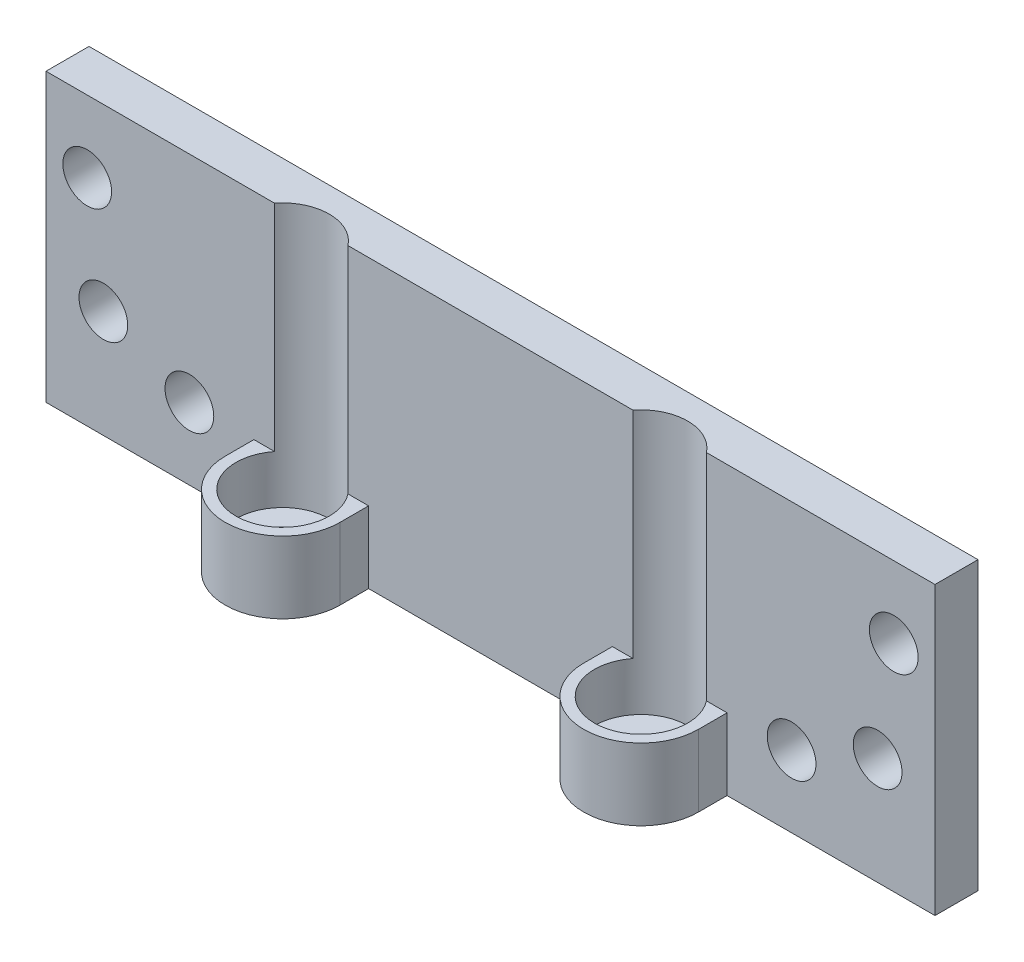
from build123d import *

# Parameters (mm, degrees)
BOSS_EXTRUDE1_DEPTH                          = 20
SKETCH2_W                                    = 33
SKETCH2_H                                    = 6
CUT_EXTRUDE1_DEPTH                           = 15
CBORE_FOR_M3_HEX_SOCKET_HEAD_CAP_SCR_2_COUNT = 2
CBORE_FOR_M3_HEX_SOCKET_HEAD_CAP_SCR_2_PITCH = 25
CUT_EXTRUDE2_DEPTH                           = 15
M3_CLEARANCE_HOLE1_D                         = 3.4
M3_CLEARANCE_HOLE1_DEPTH                     = 3


with BuildPart() as part:
    # Sketch1 → Boss-Extrude1 (new body)
    with BuildSketch(Plane(origin=(0, 0, 0), x_dir=(1, 0, 0), z_dir=(0, 1, 0))):
        with BuildLine():
            Line((-31, -1.5), (-16.5, -1.5))
            Line((-16.5, -1.5), (-16.5, -3.5))
            ThreePointArc((-16.5, -3.5), (-12.5, -7.5), (-8.5, -3.5))
            Line((-8.5, -3.5), (-8.5, -1.5))
            Line((-8.5, -1.5), (8.5, -1.5))
            Line((8.5, -1.5), (8.5, -3.5))
            ThreePointArc((8.5, -3.5), (12.5, -7.5), (16.5, -3.5))
            Line((16.5, -3.5), (16.5, -1.5))
            Line((16.5, -1.5), (31, -1.5))
            Line((31, -1.5), (31, 1.5))
            Line((31, 1.5), (-31, 1.5))
            Line((-31, 1.5), (-31, -1.5))
        make_face()
    extrude(amount=BOSS_EXTRUDE1_DEPTH)

    # Sketch2 → Cut-Extrude1 (cut)
    with BuildSketch(Plane(origin=(0, 20, 0), x_dir=(1, 0, 0), z_dir=(0, 1, 0))):
        with Locations((0, -4.5)):
            Rectangle(SKETCH2_W, SKETCH2_H)
    extrude(amount=-CUT_EXTRUDE1_DEPTH, mode=Mode.SUBTRACT)

    # Sketch4 → CBORE for M3 Hex Socket Head Cap Screw1 (revolve, cut)
    with BuildSketch(Plane(origin=(-12.5, 5, 3.5), x_dir=(0, 0, 1), z_dir=(1, 0, 0))):
        Polygon((0, 0), (0, 5), (1.6, 5), (1.6, 3.4), (3.25, 3.4), (3.25, 0), align=None)
    cbore_for_m3_hex_socket_head_cap_screw1 = revolve(axis=Axis((-12.5, 11.35, 3.5), (0, -1, 0)), mode=Mode.SUBTRACT)

    # CBORE for M3 Hex Socket Head Cap Scr 2: CBORE for M3 Hex Socket Head Cap Screw1 ×2
    with Locations(*[(i * CBORE_FOR_M3_HEX_SOCKET_HEAD_CAP_SCR_2_PITCH, 0, 0) for i in range(1, CBORE_FOR_M3_HEX_SOCKET_HEAD_CAP_SCR_2_COUNT)]):
        add(cbore_for_m3_hex_socket_head_cap_screw1, mode=Mode.SUBTRACT)

    # Sketch5 → Cut-Extrude2 (cut)
    with BuildSketch(Plane.XZ.offset(-5)):
        with BuildLine():
            Line((-9.938262309, 1.5), (-15.061737691, 1.5))
            ThreePointArc((-15.061737691, 1.5), (-12.5, 0.25), (-9.938262309, 1.5))
        make_face()
        with BuildLine():
            Line((15.061737691, 1.5), (9.938262309, 1.5))
            ThreePointArc((9.938262309, 1.5), (12.5, 0.25), (15.061737691, 1.5))
        make_face()
    extrude(amount=-CUT_EXTRUDE2_DEPTH, mode=Mode.SUBTRACT)

    # M3 Clearance Hole1
    with Locations(Plane.XY.offset(1.5)):
        with Locations((-28.125, 15), (28.125, 15), (-21, 5), (21, 5), (-27, 7.5), (27, 7.5)):
            Hole(M3_CLEARANCE_HOLE1_D / 2, depth=M3_CLEARANCE_HOLE1_DEPTH)


solid = part.part
